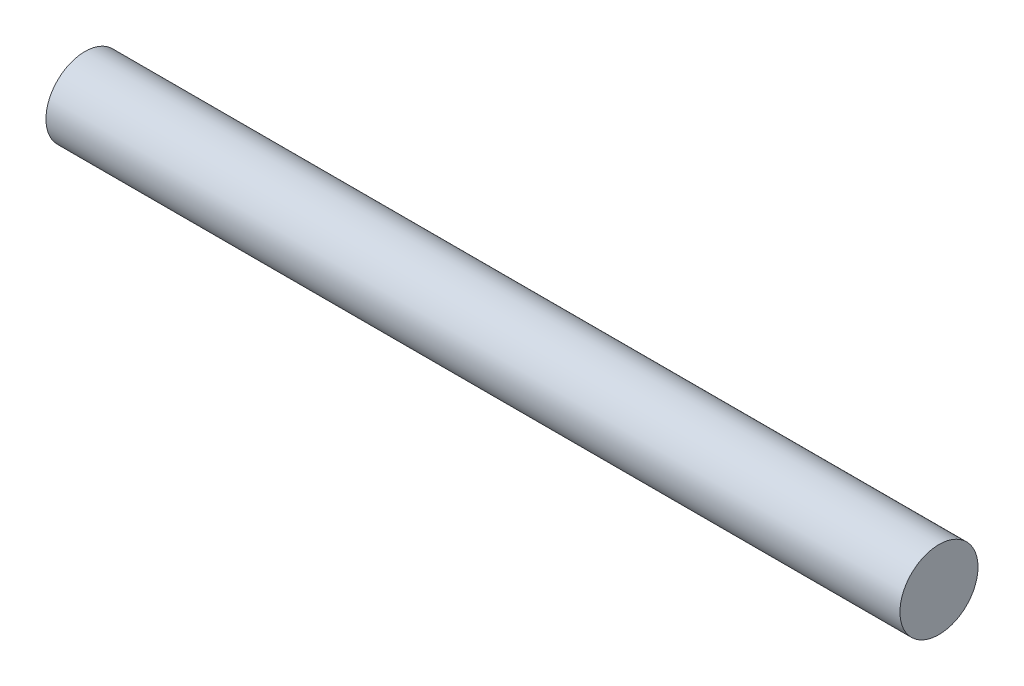
from build123d import *

# Parameters (mm, degrees)
SKETCH1_R           = 1.6
BOSS_EXTRUDE1_DEPTH = 35


with BuildPart() as part:
    # Sketch1 → Boss-Extrude1 (new body)
    with BuildSketch(Plane(origin=(0, 0, 0), x_dir=(0, 0, -1), z_dir=(1, 0, 0))):
        Circle(SKETCH1_R)
    extrude(amount=BOSS_EXTRUDE1_DEPTH)


solid = part.part
